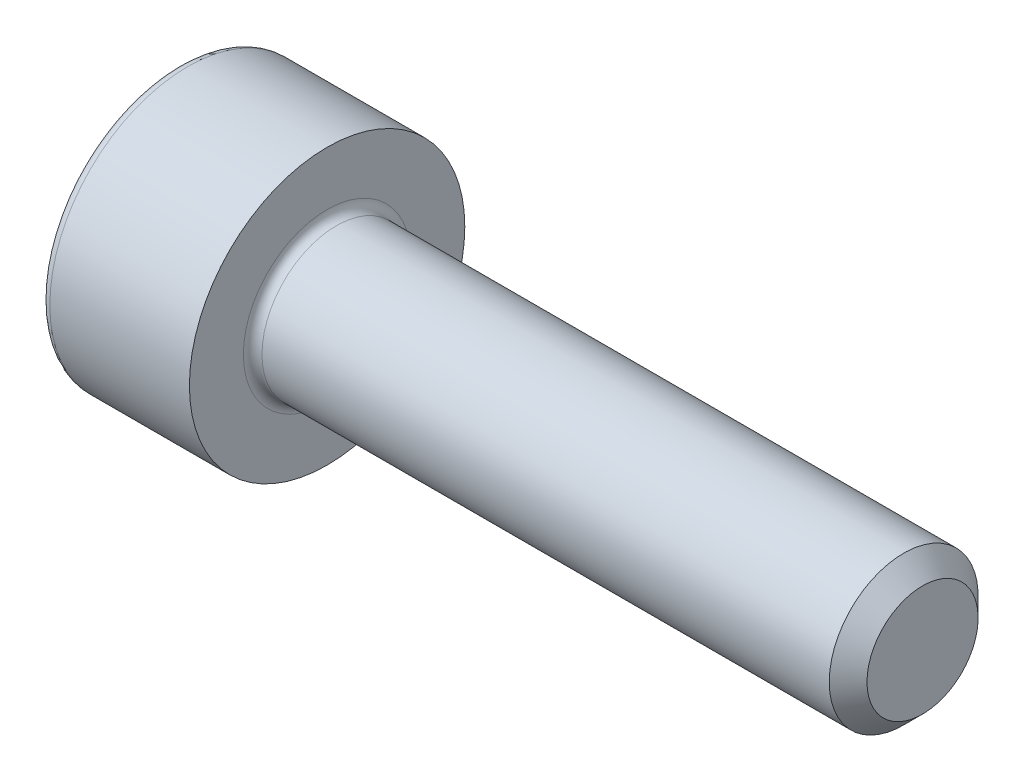
from build123d import *

# Parameters (mm, degrees)
CUT_EXTRUDE1_DEPTH = 1.1


with BuildPart() as part:
    # Sketch1 → Revolve1 (revolve)
    with BuildSketch(Plane.XY):
        with BuildLine():
            Line((7.7465, 1), (0.125, 1))
            ThreePointArc((0.125, 1), (0.036611652, 1.036611652), (0, 1.125))
            Line((0, 1.125), (0, 1.85))
            Line((0, 1.85), (-1.875, 1.85))
            ThreePointArc((-1.875, 1.85), (-1.963388348, 1.813388348), (-2, 1.725))
            Line((-2, 1.725), (-2, 0))
            Line((-2, 0), (8, 0))
            Line((8, 0), (8, 0.7465))
            Line((8, 0.7465), (7.7465, 1))
        make_face()
    revolve(axis=Axis((-2, 0, 0), (1, 0, 0)))

    # Sketch2 → Cut-Extrude1 (cut)
    with BuildSketch(Plane.ZY.offset(2)):
        Polygon((0.75, 0.433012702), (0, 0.866025404), (-0.75, 0.433012702), (-0.75, -0.433012702), (0, -0.866025404), (0.75, -0.433012702), align=None)
    extrude(amount=-CUT_EXTRUDE1_DEPTH, mode=Mode.SUBTRACT)


solid = part.part
